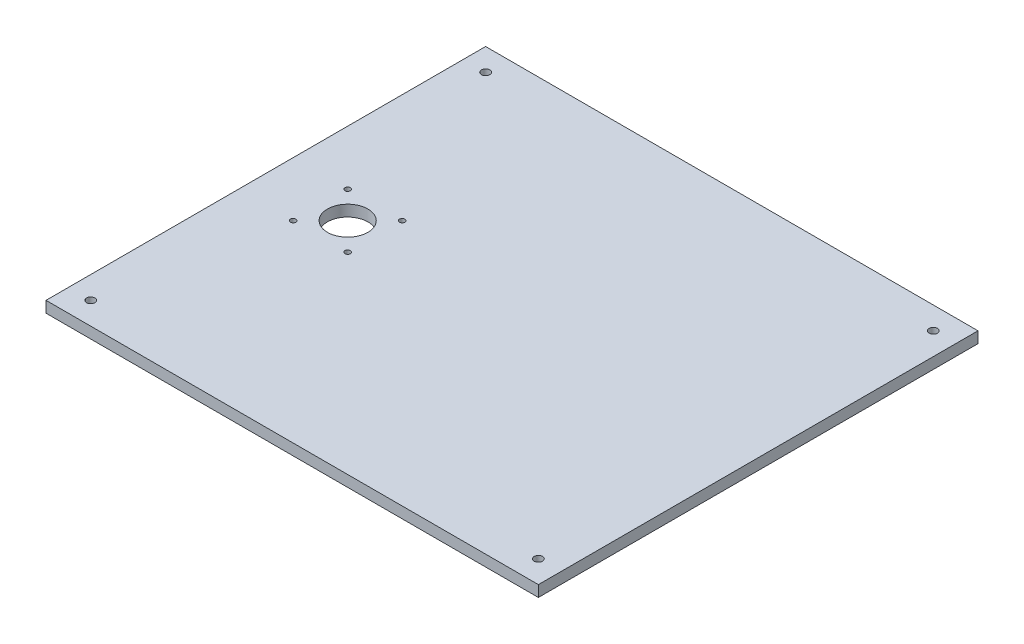
from build123d import *

# Parameters (mm, degrees)
SKETCH1_W               = 280
SKETCH1_H               = 250
BOSS_EXTRUDE1_DEPTH     = 6.35
SKETCH3_R               = 2.38125
CUT_EXTRUDE1_DEPTH      = 7.35
MIRROR2_COPY_1_SKETCH_R = 2.38125
MIRROR2_COPY_1_DEPTH    = 7.35
SKETCH7_R               = 1.55
SKETCH7_R_2             = 11.5
CUT_EXTRUDE4_DEPTH      = 7.35


with BuildPart() as part:
    # Sketch1 → Boss-Extrude1 (new body)
    with BuildSketch(Plane(origin=(0, 0, 0), x_dir=(1, 0, 0), z_dir=(0, 1, 0))):
        Rectangle(SKETCH1_W, SKETCH1_H)
    extrude(amount=BOSS_EXTRUDE1_DEPTH)

    # Sketch3 → Cut-Extrude1 (cut, through all)
    with BuildSketch(Plane(origin=(0, 6.35, 0), x_dir=(1, 0, 0), z_dir=(0, 1, 0))):
        with Locations((-127.3, -112.3)):
            Circle(SKETCH3_R)
    cut_extrude1 = extrude(amount=-CUT_EXTRUDE1_DEPTH, mode=Mode.SUBTRACT)

    # Mirror1: Cut-Extrude1 across plane
    add(cut_extrude1.mirror(Plane.XY), mode=Mode.SUBTRACT)

    # Mirror2: Cut-Extrude1 across plane
    add(cut_extrude1.mirror(Plane(origin=(0, 0, 0), x_dir=(0, 0, 1), z_dir=(1, 0, 0))), mode=Mode.SUBTRACT)

    # Mirror2 copy 1 sketch → Mirror2 copy 1 (cut, through all)
    with BuildSketch(Plane(origin=(0, 6.35, 0), x_dir=(-1, 0, 0), z_dir=(0, 1, 0))):
        with Locations((-127.3, -112.3)):
            Circle(MIRROR2_COPY_1_SKETCH_R)
    extrude(amount=-MIRROR2_COPY_1_DEPTH, mode=Mode.SUBTRACT)

    # Sketch7 → Cut-Extrude4 (cut, through all)
    with BuildSketch(Plane(origin=(0, 6.35, 0), x_dir=(-1, 0, 0), z_dir=(0, 1, 0))):
        with Locations((77.95, 15.5)):
            Circle(SKETCH7_R)
        with Locations((93.45, 0)):
            Circle(SKETCH7_R_2)
        with Locations((108.95, 15.5)):
            Circle(SKETCH7_R)
        with Locations((108.95, -15.5)):
            Circle(SKETCH7_R)
        with Locations((77.95, -15.5)):
            Circle(SKETCH7_R)
    extrude(amount=-CUT_EXTRUDE4_DEPTH, mode=Mode.SUBTRACT)


solid = part.part
